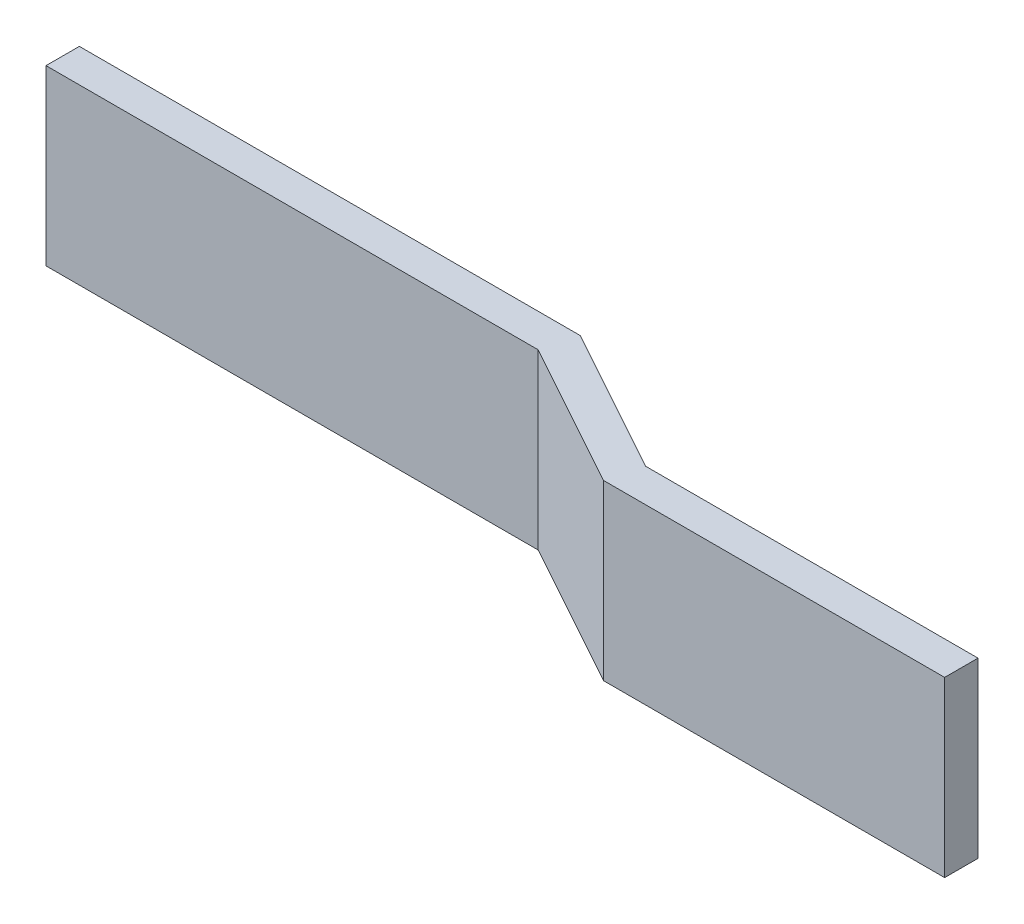
from build123d import *

# Parameters (mm, degrees)
EXTRUDE_THIN1_DEPTH = 13.208
SKETCH3_R           = 3.048
CUT_EXTRUDE1_DEPTH  = 1.27


with BuildPart() as part:
    # Sketch1 → Extrude-Thin1 (new body)
    with BuildSketch(Plane(origin=(0, 0, 0), x_dir=(1, 0, 0), z_dir=(0, 1, 0))):
        Polygon((0, 0), (38.139058105, 0), (49.245270394, -6.128868698), (74.567434413, -6.128868698), (74.567434413, -8.668868698), (48.590941352, -8.668868698), (37.484729063, -2.54), (0, -2.54), align=None)
    extrude(amount=EXTRUDE_THIN1_DEPTH)

    # Sketch3 → Cut-Extrude1 (cut)
    with BuildSketch(Plane(origin=(0, 0, 0), x_dir=(-1, 0, 0), z_dir=(0, 0, -1))):
        with Locations((-6.110625798, 6.604)):
            Circle(SKETCH3_R)
    extrude(amount=-CUT_EXTRUDE1_DEPTH, mode=Mode.SUBTRACT)


solid = part.part
